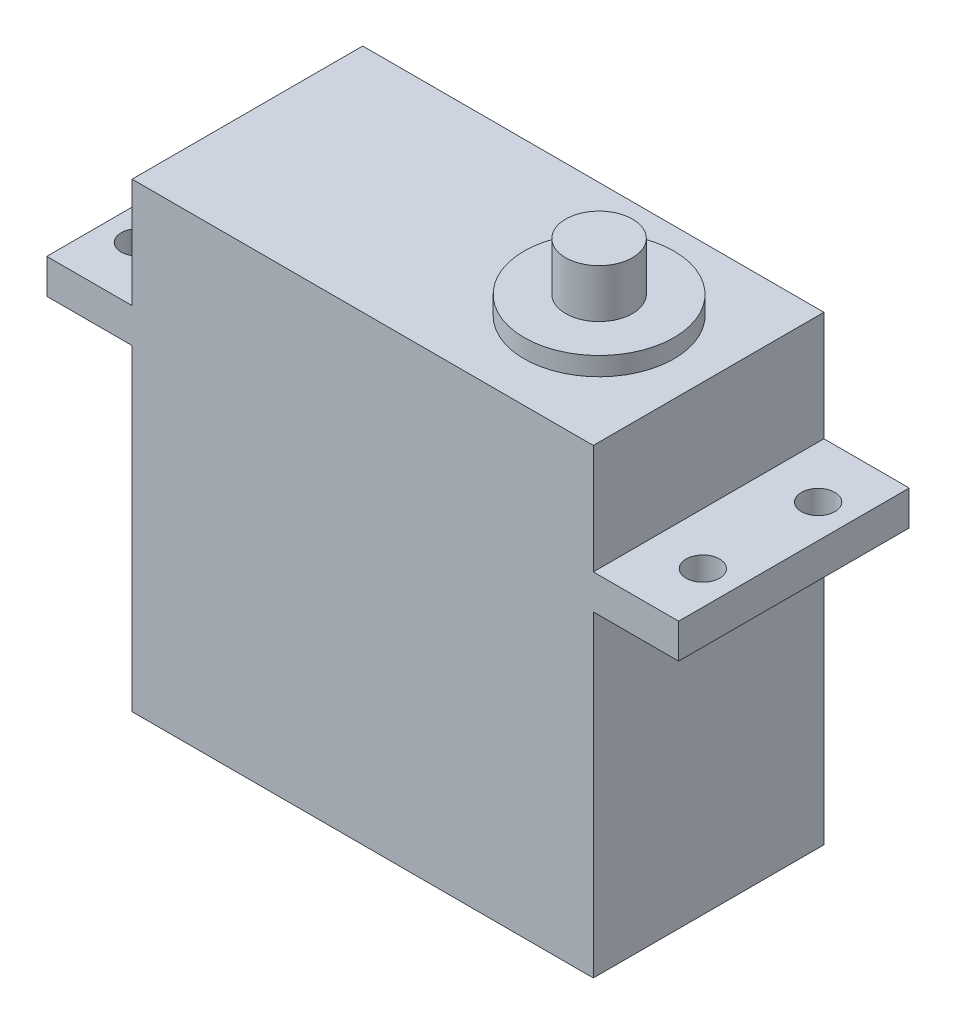
from build123d import *

# Parameters (mm, degrees)
SKETCH1_W                  = 40
SKETCH1_H                  = 20
BOSS_EXTRUDE1_DEPTH        = 40
SKETCH2_W                  = 20
SKETCH2_H                  = 3
BOSS_EXTRUDE2_DEPTH        = 7.4
SKETCH3_R                  = 2.9
BOSS_EXTRUDE3_DEPTH        = 5.8
SKETCH5_R                  = 6.5
BOSS_EXTRUDE4_DEPTH        = 1.6
M2_5_CLEARANCE_SLOT1_D     = 2.9
M2_5_CLEARANCE_SLOT1_DEPTH = 8.999
M2_5_CLEARANCE_SLOT1_TIP   = 0.871247898


with BuildPart() as part:
    # Sketch1 → Boss-Extrude1 (new body)
    with BuildSketch(Plane(origin=(0, 0, 0), x_dir=(1, 0, 0), z_dir=(0, 1, 0))):
        Rectangle(SKETCH1_W, SKETCH1_H)
    extrude(amount=BOSS_EXTRUDE1_DEPTH)

    # Sketch2 → Boss-Extrude2 (add)
    with BuildSketch(Plane(origin=(20, 0, 0), x_dir=(0, 0, -1), z_dir=(1, 0, 0))):
        with Locations((0, 29)):
            Rectangle(SKETCH2_W, SKETCH2_H)
    boss_extrude2 = extrude(amount=BOSS_EXTRUDE2_DEPTH)

    # Mirror1: Boss-Extrude2 across plane
    add(boss_extrude2.mirror(Plane(origin=(0, 0, 0), x_dir=(0, 0, 1), z_dir=(1, 0, 0))))

    # Sketch3 → Boss-Extrude3 (add)
    with BuildSketch(Plane(origin=(0, 40, 0), x_dir=(1, 0, 0), z_dir=(0, 1, 0))):
        with Locations((10.5, 0)):
            Circle(SKETCH3_R)
    extrude(amount=BOSS_EXTRUDE3_DEPTH)

    # Sketch5 → Boss-Extrude4 (add)
    with BuildSketch(Plane(origin=(0, 40, 0), x_dir=(1, 0, 0), z_dir=(0, 1, 0))):
        with Locations((10.5, 0)):
            Circle(SKETCH5_R)
    extrude(amount=BOSS_EXTRUDE4_DEPTH)

    # M2.5 Clearance Slot1
    with Locations(Plane(origin=(-162.114339431, 30.5, -5.431907662), x_dir=(0.412719532, 0, 0.91085816), z_dir=(0, 1, 0))):
        with Locations((57.189532403, 125.168887287), (66.298114004, 121.041691966), (77.412789478, 169.800937131), (86.521371079, 165.67374181)):
            Hole(M2_5_CLEARANCE_SLOT1_D / 2, depth=M2_5_CLEARANCE_SLOT1_DEPTH)
            with Locations((0, 0, -(M2_5_CLEARANCE_SLOT1_DEPTH + M2_5_CLEARANCE_SLOT1_TIP / 2))):  # 118° drill point
                Cone(0, M2_5_CLEARANCE_SLOT1_D / 2, M2_5_CLEARANCE_SLOT1_TIP, mode=Mode.SUBTRACT)


solid = part.part
